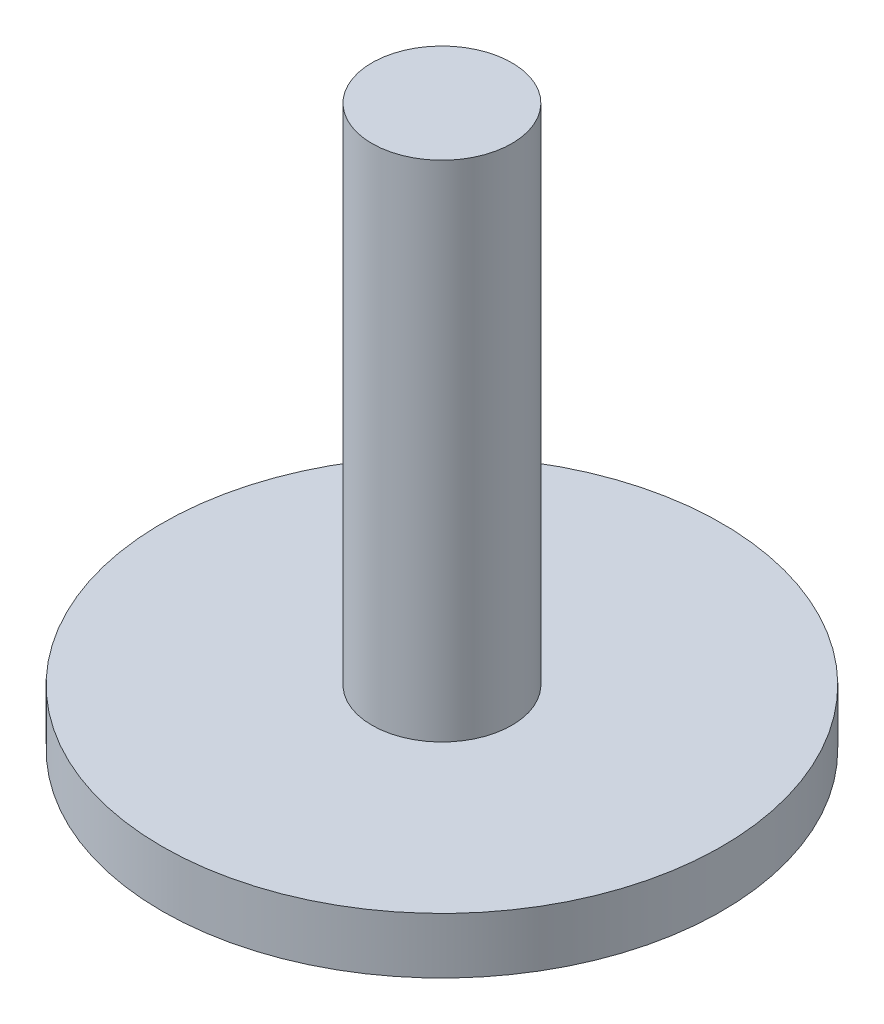
from build123d import *

# Parameters (mm, degrees)
CENTER_SHAFT_R          = 0.635
CENTER_SHAFT_EXTR_DEPTH = 5.08
TOP_LANDING_R           = 2.54
TOP_LANDING_EXTR_DEPTH  = 0.508


with BuildPart() as part:
    # Center Shaft → Center Shaft extr (new body)
    with BuildSketch(Plane(origin=(0, 0, 0), x_dir=(1, 0, 0), z_dir=(0, 1, 0))):
        Circle(CENTER_SHAFT_R)
    extrude(amount=CENTER_SHAFT_EXTR_DEPTH)

    # Top Landing → Top landing extr (add)
    with BuildSketch(Plane(origin=(0, 0, 0), x_dir=(1, 0, 0), z_dir=(0, 1, 0))):
        Circle(TOP_LANDING_R)
    extrude(amount=TOP_LANDING_EXTR_DEPTH)


solid = part.part
